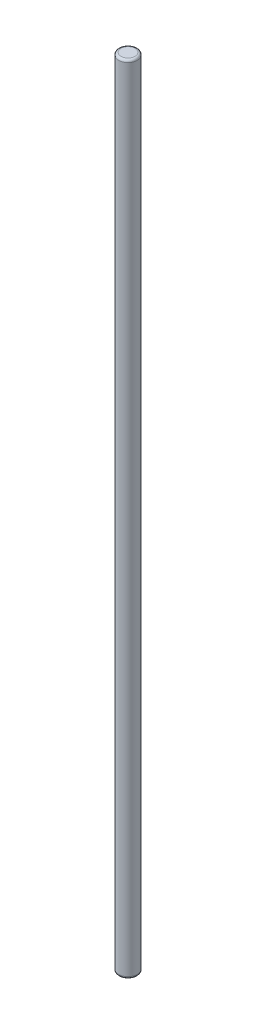
from build123d import *

# Parameters (mm, degrees)
SKETCH1_R           = 4
BOSS_EXTRUDE1_DEPTH = 342
FILLET2_R           = 1


with BuildPart() as part:
    # Sketch1 → Boss-Extrude1 (new body)
    with BuildSketch(Plane(origin=(0, 0, 0), x_dir=(1, 0, 0), z_dir=(0, 1, 0))):
        Circle(SKETCH1_R)
    extrude(amount=BOSS_EXTRUDE1_DEPTH)

    # Fillet2
    fillet2_edges = [part.edges().sort_by_distance(p)[0] for p in [
        (-4, 0, 0),
        (-4, 342, 0),
    ]]
    fillet(fillet2_edges, radius=FILLET2_R)


solid = part.part
